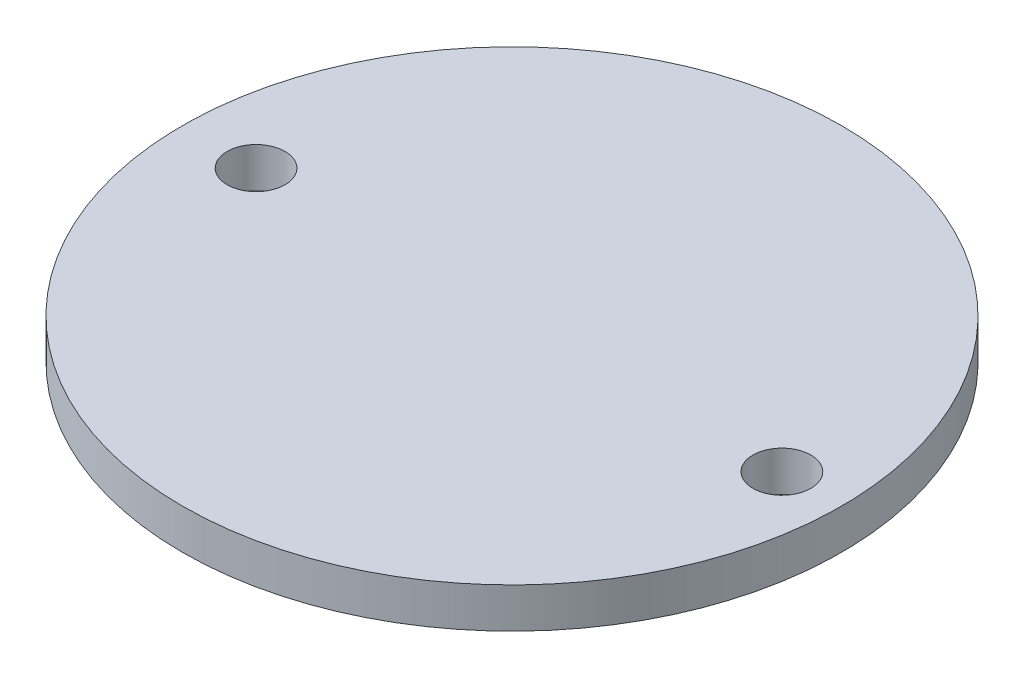
from build123d import *

# Parameters (mm, degrees)
SKETCH1_R           = 12.5349
BOSS_EXTRUDE1_DEPTH = 0.762
SKETCH2_R           = 1.1
CUT_EXTRUDE1_DEPTH  = 2.524


with BuildPart() as part:
    # Sketch1 → Boss-Extrude1 (new body, symmetric)
    with BuildSketch(Plane(origin=(0, 0, 0), x_dir=(1, 0, 0), z_dir=(0, 1, 0))):
        Circle(SKETCH1_R)
    extrude(amount=BOSS_EXTRUDE1_DEPTH, both=True)

    # Sketch2 → Cut-Extrude1 (cut, through all)
    with BuildSketch(Plane(origin=(0, 0.762, 0), x_dir=(1, 0, 0), z_dir=(0, 1, 0))):
        with Locations((-9.734900012, 0)):
            Circle(SKETCH2_R)
        with Locations((10.265099988, 0)):
            Circle(SKETCH2_R)
    extrude(amount=-CUT_EXTRUDE1_DEPTH, mode=Mode.SUBTRACT)


solid = part.part
